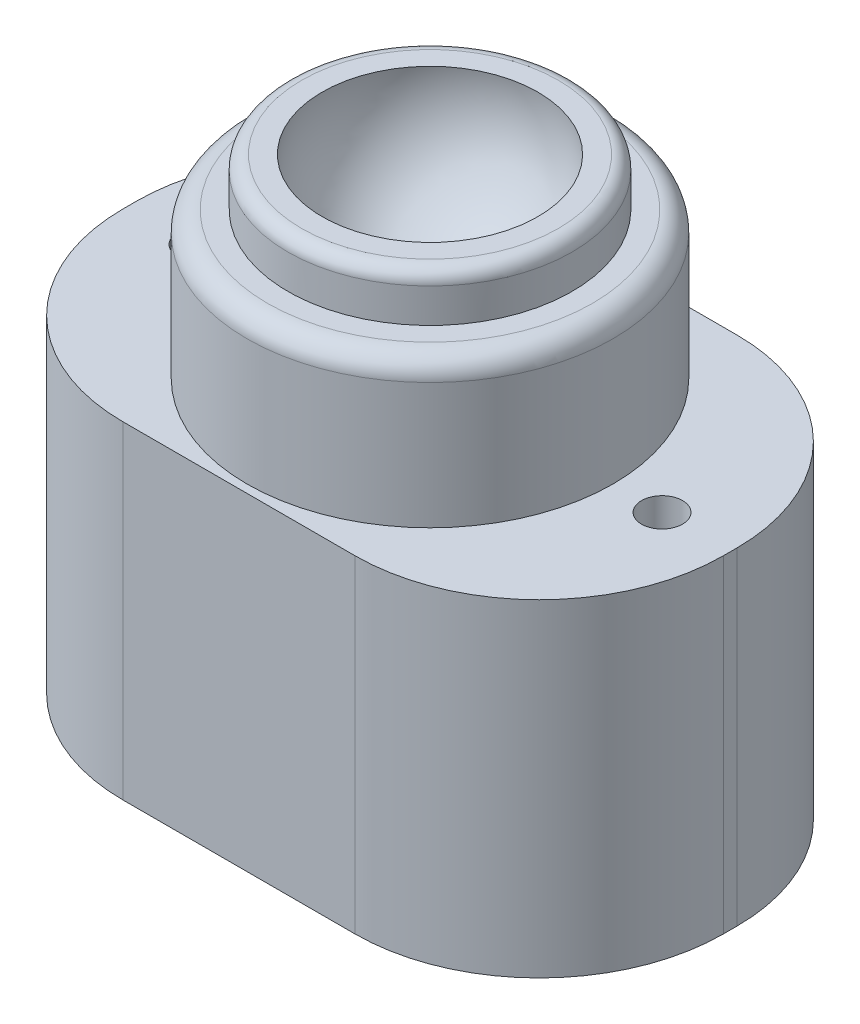
from build123d import *

# Parameters (mm, degrees)
FILLET1_R           = 1
FILLET2_R           = 1.5
SKETCH5_W           = 44
SKETCH5_H           = 28
BOSS_EXTRUDE1_DEPTH = 24
FILLET3_R           = 13.5
SKETCH7_R           = 1.5
CUT_EXTRUDE1_DEPTH  = 25


with BuildPart() as part:
    # Sketch1 → Revolve2 (revolve)
    with BuildSketch(Plane.XY):
        with BuildLine():
            Line((0, 0), (0, 5))
            ThreePointArc((0, 5), (6.071429533, 7.79069576), (7.907014302, 14.215714666))
            Line((7.907014302, 14.215714666), (10.407014302, 14.215714666))
            Line((10.407014302, 14.215714666), (10.407014302, 10.715714666))
            Line((10.407014302, 10.715714666), (13.407014302, 10.715714666))
            Line((13.407014302, 10.715714666), (13.407014302, 0))
            Line((13.407014302, 0), (0, 0))
        make_face()
    revolve(axis=Axis((0, 0, 0), (0, 1, 0)))

    # Fillet1
    fillet1_edges = [part.edges().sort_by_distance(p)[0] for p in [
        (-10.407014302, 14.215714666, 0),
    ]]
    fillet(fillet1_edges, radius=FILLET1_R)

    # Fillet2
    fillet2_edges = [part.edges().sort_by_distance(p)[0] for p in [
        (-13.407014302, 10.715714666, 0),
    ]]
    fillet(fillet2_edges, radius=FILLET2_R)

    # Sketch5 → Boss-Extrude1 (add)
    with BuildSketch(Plane(origin=(0, 0, 0), x_dir=(1, 0, 0), z_dir=(0, 1, 0))):
        Rectangle(SKETCH5_W, SKETCH5_H)
    extrude(amount=-BOSS_EXTRUDE1_DEPTH)

    # Fillet3
    fillet3_edges = [part.edges().sort_by_distance(p)[0] for p in [
        (-22, -12, 14),
        (-22, -12, -14),
        (22, -12, -14),
        (22, -12, 14),
    ]]
    fillet(fillet3_edges, radius=FILLET3_R)

    # Sketch7 → Cut-Extrude1 (cut, through all)
    with BuildSketch(Plane(origin=(0, 0, 0), x_dir=(1, 0, 0), z_dir=(0, 1, 0))):
        with Locations((-17, 0)):
            Circle(SKETCH7_R)
    cut_extrude1 = extrude(amount=-CUT_EXTRUDE1_DEPTH, mode=Mode.SUBTRACT)

    # Mirror1: Cut-Extrude1 across plane
    add(cut_extrude1.mirror(Plane.ZY), mode=Mode.SUBTRACT)


solid = part.part
